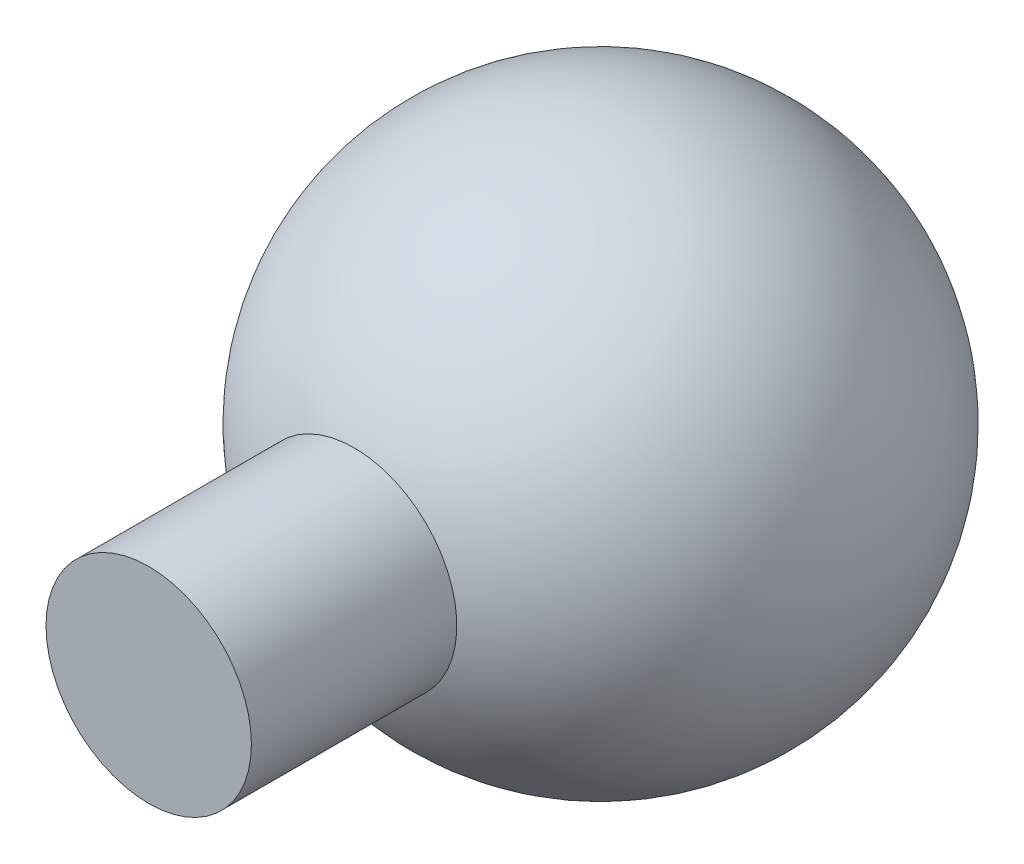
from build123d import *

# Parameters (mm, degrees)
SKETCH2_R           = 2.5
BOSS_EXTRUDE1_DEPTH = 11


with BuildPart() as part:
    # Sketch1 → Revolve1 (revolve)
    with BuildSketch(Plane.XY):
        with BuildLine():
            Line((0, 6.5), (0, -6.5))
            ThreePointArc((0, -6.5), (6.5, 0), (0, 6.5))
        make_face()
    revolve(axis=Axis((0, 11.820812498, 0), (0, -1, 0)))

    # Sketch2 → Boss-Extrude1 (add)
    with BuildSketch(Plane.XY):
        Circle(SKETCH2_R)
    extrude(amount=BOSS_EXTRUDE1_DEPTH)


solid = part.part
